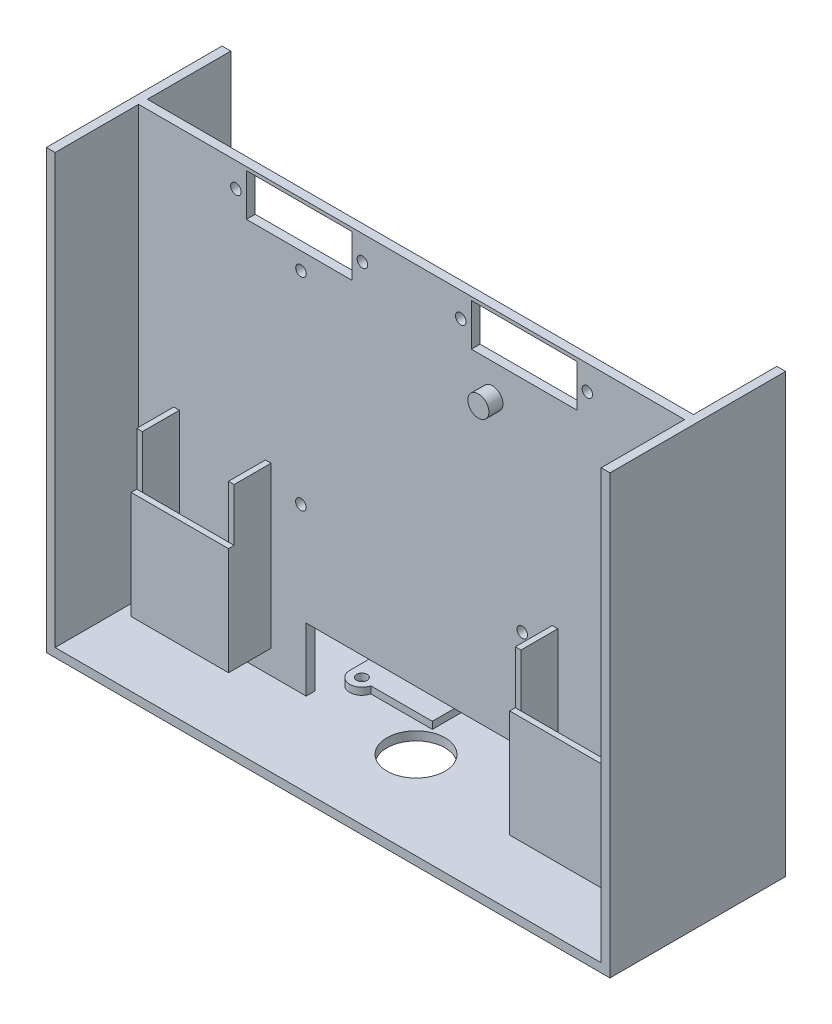
from build123d import *

# Parameters (mm, degrees)
SKETCH1_W           = 155.4
SKETCH1_H           = 122
SKETCH1_R           = 1.5
SKETCH1_W_2         = 30
SKETCH1_H_2         = 12
BOSS_EXTRUDE1_DEPTH = 2.5
SKETCH1_5_R         = 3
BOSS_EXTRUDE2_DEPTH = 6.5
BOSS_EXTRUDE3_DEPTH = 13
SKETCH2_W           = 27.7
SKETCH2_H           = 30.6
BOSS_EXTRUDE4_DEPTH = 1.6
SKETCH3_W           = 155.4
SKETCH3_H           = 50
SKETCH3_R           = 8.25
BOSS_EXTRUDE5_DEPTH = 2.5
SKETCH4_W           = 60
SKETCH4_H           = 18
CUT_EXTRUDE1_DEPTH  = 10
SKETCH6_R           = 1.5
BOSS_EXTRUDE6_DEPTH = 2
SKETCH7_W           = 50
SKETCH7_H           = 124.5
BOSS_EXTRUDE7_DEPTH = 2.5
SKETCH8_W           = 50
SKETCH8_H           = 124.5
BOSS_EXTRUDE8_DEPTH = 2.5


with BuildPart() as part:
    # Sketch1 → Boss-Extrude1 (new body)
    with BuildSketch(Plane.XY):
        with Locations((77.7, 61)):
            Rectangle(SKETCH1_W, SKETCH1_H)
        with Locations((46.2, 46.5)):
            Circle(SKETCH1_R, mode=Mode.SUBTRACT)
        with Locations((109.2, 46.5)):
            Circle(SKETCH1_R, mode=Mode.SUBTRACT)
        with Locations((27.7, 115)):
            Circle(SKETCH1_R, mode=Mode.SUBTRACT)
        with Locations((46.223, 104.1)):
            Circle(SKETCH1_R, mode=Mode.SUBTRACT)
        with Locations((45.7, 115)):
            Rectangle(SKETCH1_W_2, SKETCH1_H_2, mode=Mode.SUBTRACT)
        with Locations((63.7, 115)):
            Circle(SKETCH1_R, mode=Mode.SUBTRACT)
        with Locations((91.7, 115)):
            Circle(SKETCH1_R, mode=Mode.SUBTRACT)
        with Locations((109.7, 115)):
            Rectangle(SKETCH1_W_2, SKETCH1_H_2, mode=Mode.SUBTRACT)
        with Locations((127.7, 115)):
            Circle(SKETCH1_R, mode=Mode.SUBTRACT)
    extrude(amount=BOSS_EXTRUDE1_DEPTH)

    # Sketch1_5 → Boss-Extrude2 (add)
    with BuildSketch(Plane.XY):
        with Locations((100.7, 100)):
            Circle(SKETCH1_5_R)
    extrude(amount=BOSS_EXTRUDE2_DEPTH)

    # Sketch1_6 → Boss-Extrude3 (add)
    with BuildSketch(Plane.XY):
        Polygon((145.4, 6.8), (145.4, 52.4), (143.8, 52.4), (143.8, 8.4), (119.3, 8.4), (119.3, 52.4), (117.7, 52.4), (117.7, 6.8), align=None)
        Polygon((10, 52.4), (10, 6.8), (37.7, 6.8), (37.7, 52.4), (36.1, 52.4), (36.1, 8.4), (11.6, 8.4), (11.6, 52.4), align=None)
    extrude(amount=BOSS_EXTRUDE3_DEPTH)

    # Sketch2 → Boss-Extrude4 (add)
    with BuildSketch(Plane.XY.offset(13)):
        with Locations((23.85, 22.1)):
            Rectangle(SKETCH2_W, SKETCH2_H)
        with Locations((131.55, 22.1)):
            Rectangle(SKETCH2_W, SKETCH2_H)
    extrude(amount=BOSS_EXTRUDE4_DEPTH)

    # Sketch3 → Boss-Extrude5 (add)
    with BuildSketch(Plane.XZ):
        with Locations((77.7, 1.25)):
            Rectangle(SKETCH3_W, SKETCH3_H)
        with Locations((77.7, 1.25)):
            Circle(SKETCH3_R, mode=Mode.SUBTRACT)
    extrude(amount=BOSS_EXTRUDE5_DEPTH)

    # Sketch4 → Cut-Extrude1 (cut)
    with BuildSketch(Plane.XY.offset(2.5)):
        with Locations((77.7, 9)):
            Rectangle(SKETCH4_W, SKETCH4_H)
    extrude(amount=-CUT_EXTRUDE1_DEPTH, mode=Mode.SUBTRACT)

    # Sketch6 → Boss-Extrude6 (add)
    with BuildSketch(Plane.XZ.offset(-18)):
        with BuildLine():
            Line((89.85, 8.759024603), (72.353800708, 8.759024603))
            ThreePointArc((72.353800708, 8.759024603), (68.592638026, 11.375865762), (65.55, 7.95))
            Line((65.55, 7.95), (65.55, -8.65))
            Line((65.55, -8.65), (89.85, -8.65))
            Line((89.85, -8.65), (89.85, 8.759024603))
        make_face()
        with Locations((69, 7.95)):
            Circle(SKETCH6_R, mode=Mode.SUBTRACT)
        with Locations((86.4, -5.45)):
            Circle(SKETCH6_R, mode=Mode.SUBTRACT)
    extrude(amount=BOSS_EXTRUDE6_DEPTH)

    # Sketch7 → Boss-Extrude7 (add)
    with BuildSketch(Plane(origin=(155.4, 0, 0), x_dir=(0, 0, -1), z_dir=(1, 0, 0))):
        with Locations((-1.25, 59.75)):
            Rectangle(SKETCH7_W, SKETCH7_H)
    extrude(amount=BOSS_EXTRUDE7_DEPTH)

    # Sketch8 → Boss-Extrude8 (add)
    with BuildSketch(Plane.ZY):
        with Locations((1.25, 59.75)):
            Rectangle(SKETCH8_W, SKETCH8_H)
    extrude(amount=BOSS_EXTRUDE8_DEPTH)


solid = part.part
